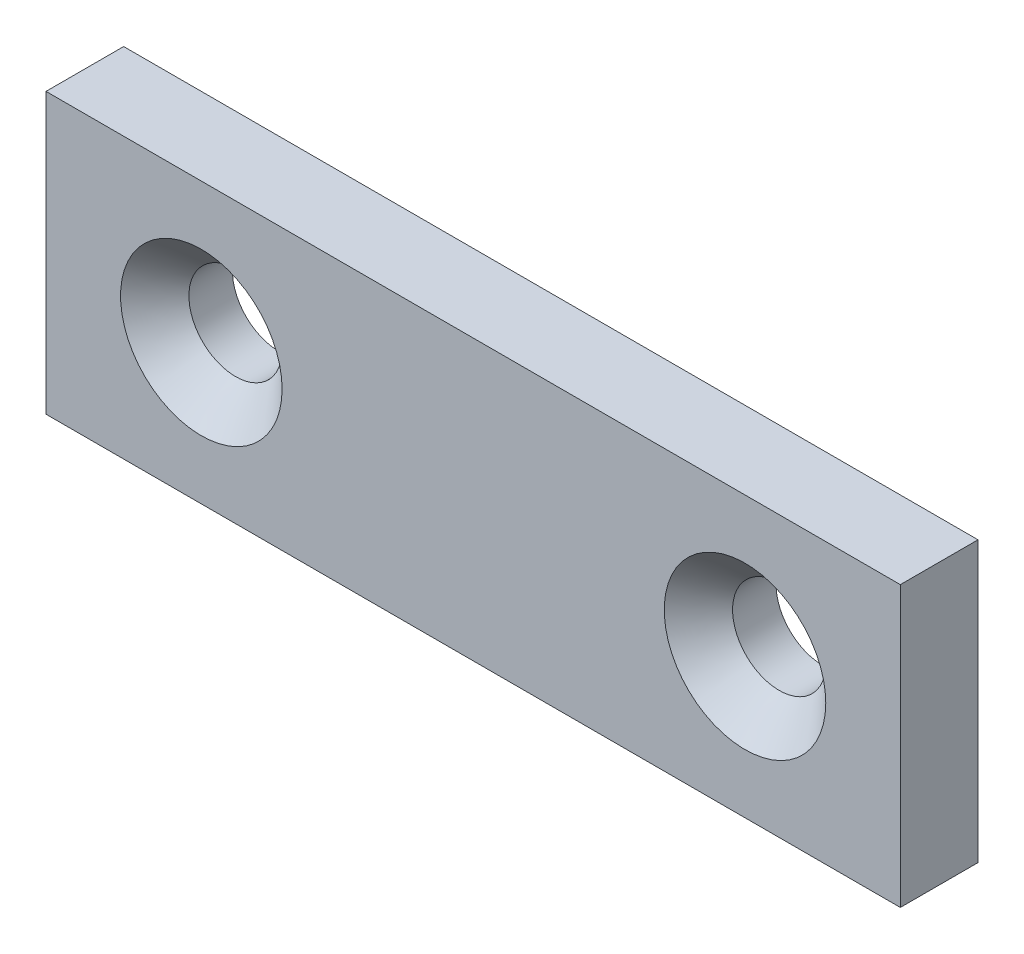
from build123d import *

# Parameters (mm, degrees)
SKETCH2_W                      = 55
SKETCH2_H                      = 18
BOSS_EXTRUDE1_DEPTH            = 2.5
F_6_0MM_DOWEL_HOLE1_AT_2_COUNT = 2
F_6_0MM_DOWEL_HOLE1_AT_2_PITCH = 35


with BuildPart() as part:
    # Sketch2 → Boss-Extrude1 (new body, symmetric)
    with BuildSketch(Plane.XY):
        with Locations((27.5, 9)):
            Rectangle(SKETCH2_W, SKETCH2_H)
    extrude(amount=BOSS_EXTRUDE1_DEPTH, both=True)

    # Sketch3 → Ø6.0mm Dowel Hole1 (revolve, cut)
    with BuildSketch(Plane(origin=(10, 9, 2.5), x_dir=(0, -1, 0), z_dir=(1, 0, 0))):
        Polygon((0, 0), (0, 5), (3, 5), (3, 2.2), (5.2, 0), align=None)
    f_6_0mm_dowel_hole1 = revolve(axis=Axis((10, 9, 8.85), (0, 0, -1)), mode=Mode.SUBTRACT)

    # Ø6.0mm Dowel Hole1 at 2: Ø6.0mm Dowel Hole1 ×2
    with Locations(*[(i * F_6_0MM_DOWEL_HOLE1_AT_2_PITCH, 0, 0) for i in range(1, F_6_0MM_DOWEL_HOLE1_AT_2_COUNT)]):
        add(f_6_0mm_dowel_hole1, mode=Mode.SUBTRACT)


solid = part.part
